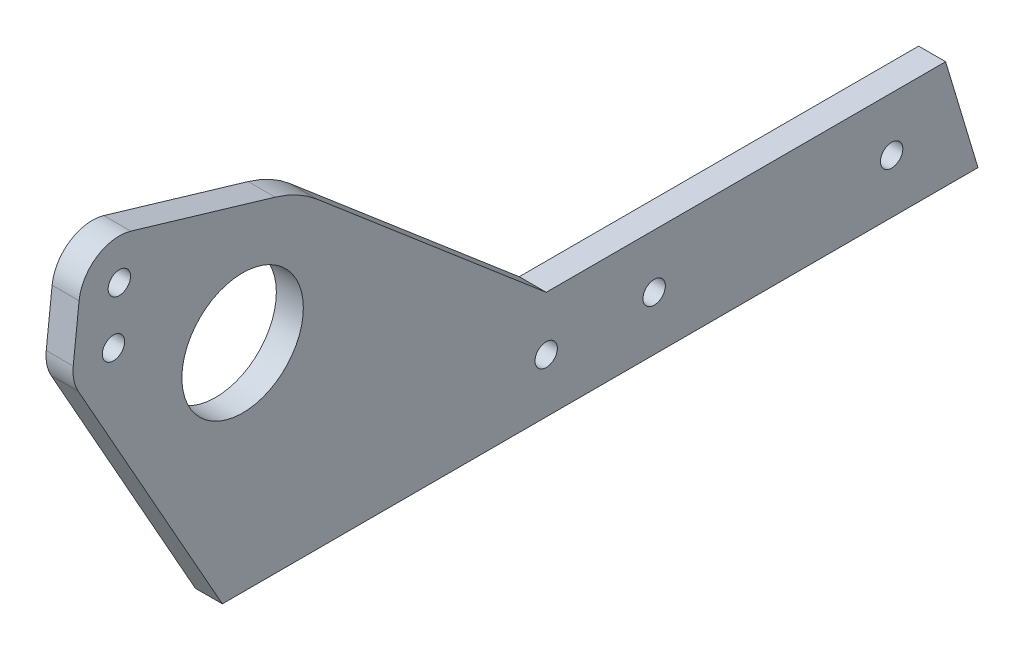
from build123d import *

# Parameters (mm, degrees)
SKETCH1_R           = 14.2875
SKETCH1_R_2         = 2.6289
BOSS_EXTRUDE1_DEPTH = 6.35


with BuildPart() as part:
    # Sketch1 → Boss-Extrude1 (new body)
    with BuildSketch(Plane(origin=(0, 0, 0), x_dir=(0, 0, -1), z_dir=(1, 0, 0))):
        with BuildLine():
            Line((-12.7, -12.7), (-88.9, -12.7))
            Line((-88.9, -12.7), (-122.826729432, 47.599537172))
            ThreePointArc((-122.826729432, 47.599537172), (-123.857351192, 50.361897296), (-123.993843813, 53.307094137))
            Line((-123.993843813, 53.307094137), (-122.611234502, 65.931609632))
            ThreePointArc((-122.611234502, 65.931609632), (-118.418396066, 72.825240039), (-110.43997975, 74.028114691))
            Line((-110.43997975, 74.028114691), (-76.479373631, 63.978142452))
            ThreePointArc((-76.479373631, 63.978142452), (-71.278861085, 61.827211414), (-66.637517322, 58.644482532))
            Line((-66.637517322, 58.644482532), (-12.7, 12.7))
            Line((-12.7, 12.7), (25.4, 12.7))
            Line((25.4, 12.7), (81.28, 12.7))
            Line((81.28, 12.7), (88.9, -12.7))
            Line((88.9, -12.7), (25.4, -12.7))
            Line((25.4, -12.7), (-12.7, -12.7))
        make_face()
        with Locations((-84.1375, 38.1)):
            Circle(SKETCH1_R, mode=Mode.SUBTRACT)
        with Locations((-12.7, 0)):
            Circle(SKETCH1_R_2, mode=Mode.SUBTRACT)
        with Locations((12.7, 0)):
            Circle(SKETCH1_R_2, mode=Mode.SUBTRACT)
        with Locations((68.58, 0)):
            Circle(SKETCH1_R_2, mode=Mode.SUBTRACT)
        with Locations((-113.142847881, 64.894652649)):
            Circle(SKETCH1_R_2, mode=Mode.SUBTRACT)
        with Locations((-114.525457191, 52.270137154)):
            Circle(SKETCH1_R_2, mode=Mode.SUBTRACT)
    extrude(amount=BOSS_EXTRUDE1_DEPTH)


solid = part.part
